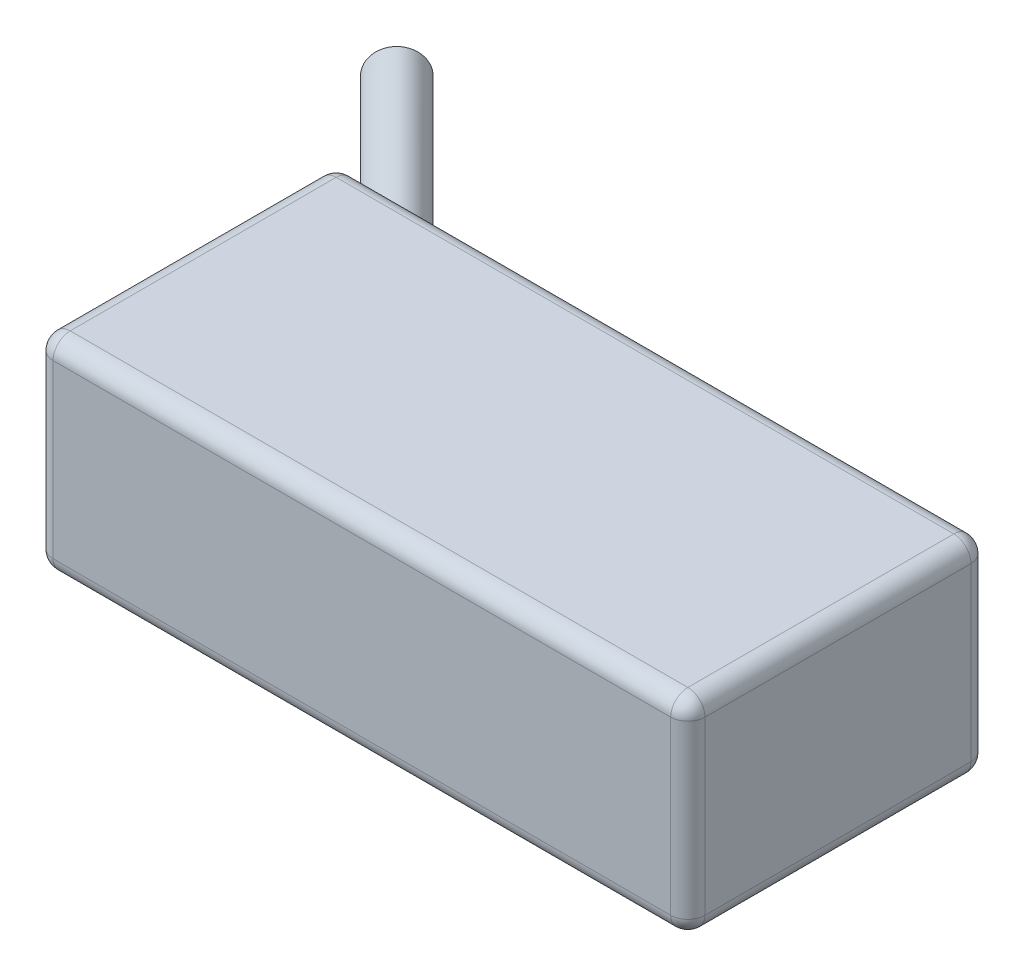
from build123d import *

# Parameters (mm, degrees)
SKETCH1_W           = 76
SKETCH1_H           = 35
BOSS_EXTRUDE1_DEPTH = 12
SKETCH4_R           = 3
BOSS_EXTRUDE2_DEPTH = 30
FILLET1_R           = 2


with BuildPart() as part:
    # Sketch1 → Boss-Extrude1 (new body, symmetric)
    with BuildSketch(Plane(origin=(0, 0, 0), x_dir=(1, 0, 0), z_dir=(0, 1, 0))):
        Rectangle(SKETCH1_W, SKETCH1_H)
    extrude(amount=BOSS_EXTRUDE1_DEPTH, both=True)

    # Sketch4 → Boss-Extrude2 (add)
    with BuildSketch(Plane(origin=(-22.75, 0, -22.75), x_dir=(0.707106781, 0, -0.707106781), z_dir=(0.707106781, 0, 0.707106781))):
        with Locations((-9.495689014, 4)):
            Circle(SKETCH4_R)
        with Locations((-9.495689014, -4)):
            Circle(SKETCH4_R)
    extrude(amount=-BOSS_EXTRUDE2_DEPTH)

    # Fillet1
    fillet1_edges = [part.edges().sort_by_distance(p)[0] for p in [
        (-38, 12, 0),
        (0, 12, 17.5),
        (38, 12, 0),
        (0, -12, 17.5),
        (-38, -12, 0),
        (0, -12, -17.5),
        (38, -12, 0),
        (38, 0, 17.5),
        (-38, 0, 17.5),
        (-38, 0, -17.5),
        (38, 0, -17.5),
        (0, 12, -17.5),
    ]]
    fillet(fillet1_edges, radius=FILLET1_R)


solid = part.part
